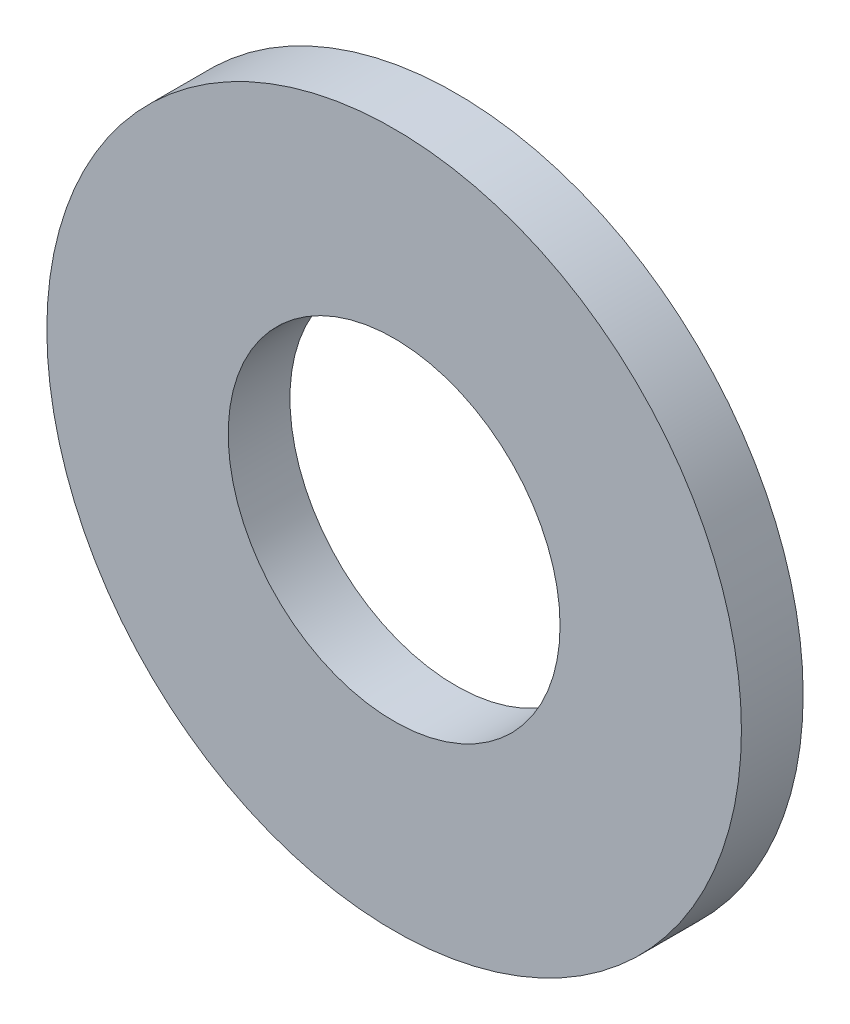
from build123d import *

# Parameters (mm, degrees)
SKETCH1_R          = 4.5
SKETCH1_R_2        = 2.15
BASE_EXTRUDE_DEPTH = 0.8


with BuildPart() as part:
    # Sketch1 → Base-Extrude (new body)
    with BuildSketch(Plane.XY):
        Circle(SKETCH1_R)
        Circle(SKETCH1_R_2, mode=Mode.SUBTRACT)
    extrude(amount=-BASE_EXTRUDE_DEPTH)


solid = part.part
